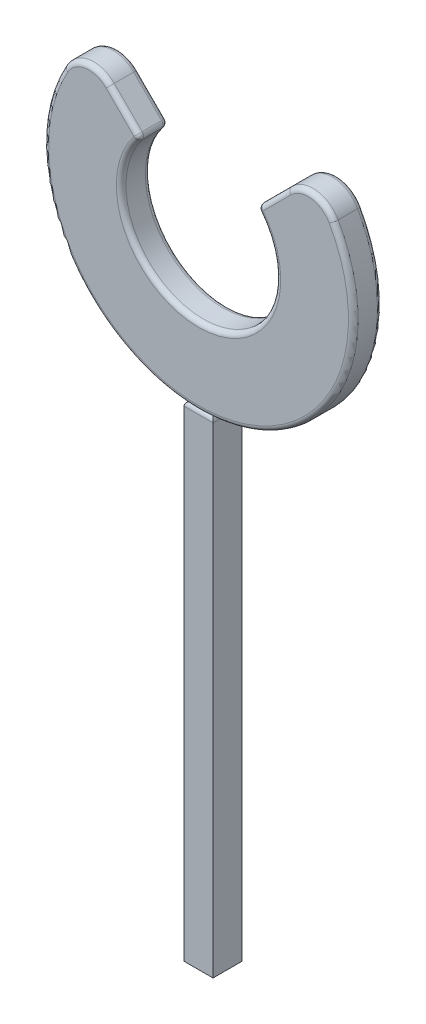
from build123d import *

# Parameters (mm, degrees)
SKETCH1_R                = 16
SKETCH1_R_2              = 8
BOSS_EXTRUDE1_DEPTH      = 3
CUT_EXTRUDE1_DEPTH       = 3
FILLET1_R                = 3
FILLET2_R                = 0.5
SKETCH3_W                = 3
SKETCH3_H                = 3
BOSS_EXTRUDE2_DEPTH      = 50
BOSS_EXTRUDE2_DEPTH_BACK = 0.2
FILLET3_R                = 0.5


with BuildPart() as part:
    # Sketch1 → Boss-Extrude1 (new body)
    with BuildSketch(Plane.XY):
        Circle(SKETCH1_R)
        Circle(SKETCH1_R_2, mode=Mode.SUBTRACT)
    extrude(amount=BOSS_EXTRUDE1_DEPTH)

    # Sketch2 → Cut-Extrude1 (cut)
    with BuildSketch(Plane.XY.offset(3)):
        Polygon((-6, 5.291502622), (6, 5.291502622), (18, 17.291502622), (-18, 17.291502622), align=None)
    extrude(amount=-CUT_EXTRUDE1_DEPTH, mode=Mode.SUBTRACT)

    # Fillet1
    fillet1_edges = [part.edges().sort_by_distance(p)[0] for p in [
        (-11.662409807, 10.953912429, 1.5),
        (11.662409807, 10.953912429, 1.5),
    ]]
    fillet(fillet1_edges, radius=FILLET1_R)

    # Fillet2
    fillet2_edges = [part.edges().sort_by_distance(p)[0] for p in [
        (0, -8, 0),
        (-6, 5.291502622, 1.5),
        (7.603509946, 6.895012568, 0),
        (7.603509946, 6.895012568, 3),
        (6, 5.291502622, 1.5),
        (0, -16, 3),
        (0, -16, 0),
        (-7.603509946, 6.895012568, 0),
        (11.736083466, 9.349363918, 0),
        (-11.736083466, 9.349363918, 0),
        (-7.603509946, 6.895012568, 3),
        (11.736083466, 9.349363918, 3),
        (-11.736083466, 9.349363918, 3),
        (0, -8, 3),
    ]]
    fillet(fillet2_edges, radius=FILLET2_R)


with BuildPart() as body_2:
    # Sketch3 → Boss-Extrude2 (new body, two sides)
    with BuildSketch(Plane(origin=(0, -16, 0), x_dir=(-1, 0, 0), z_dir=(0, -1, 0))) as boss_extrude2_sk:
        with Locations((0, -1.5)):
            Rectangle(SKETCH3_W, SKETCH3_H)
    extrude(amount=BOSS_EXTRUDE2_DEPTH)
    extrude(boss_extrude2_sk.sketch, amount=-BOSS_EXTRUDE2_DEPTH_BACK)

    # Fillet3
    fillet3_edges = [body_2.edges().sort_by_distance(p)[0] for p in [
        (1.5, -15.8, 1.5),
        (0, -15.8, 3),
        (-1.5, -15.8, 1.5),
        (0, -15.8, 0),
    ]]
    fillet(fillet3_edges, radius=FILLET3_R)


solid = Compound([part.part, body_2.part])
